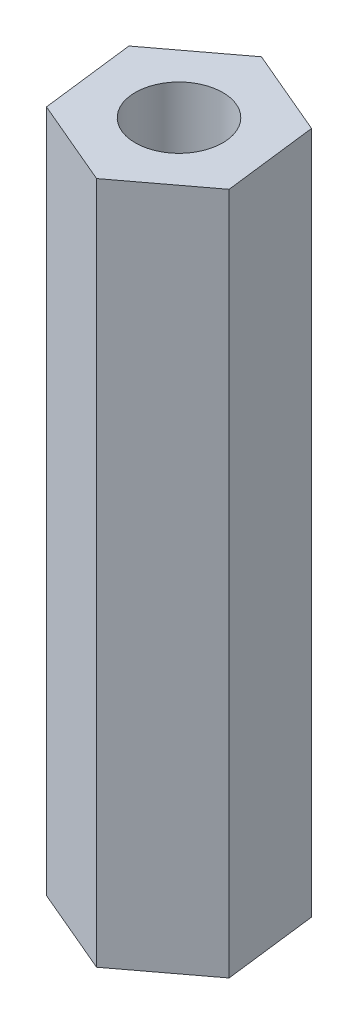
from build123d import *

# Parameters (mm, degrees)
SKETCH_1_R      = 1.6
EXTRUDE_1_DEPTH = 25


with BuildPart() as part:
    # 草图1 → 凸台-拉伸1 (new body)
    with BuildSketch(Plane(origin=(0, 0, 0), x_dir=(1, 0, 0), z_dir=(0, 1, 0))):
        Polygon((2.767176381, 2.083922954), (-0.421142027, 3.438406519), (-3.188318408, 1.354483566), (-2.767176381, -2.083922954), (0.421142027, -3.438406519), (3.188318408, -1.354483566), align=None)
        Circle(SKETCH_1_R, mode=Mode.SUBTRACT)
    extrude(amount=EXTRUDE_1_DEPTH)


solid = part.part
